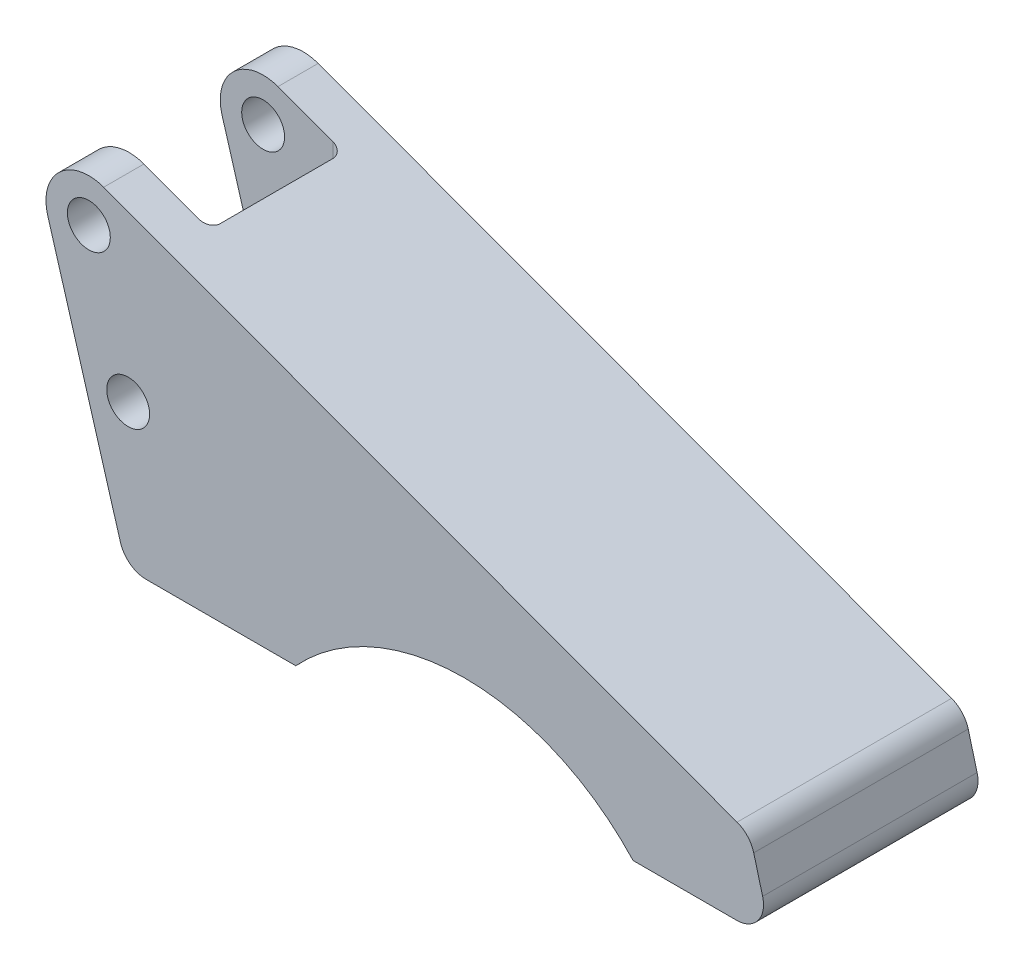
from build123d import *

# Parameters (mm, degrees)
SKETCH1_R               = 4
BOSS_EXTRUDE1_DEPTH     = 40
FILLET1_R               = 5
SKETCH2_W               = 25
SKETCH2_H               = 25
CUT_EXTRUDE1_DEPTH      = 9
CUT_EXTRUDE1_DEPTH_BACK = 52.87
FILLET2_R               = 2


with BuildPart() as part:
    # Sketch1 → Boss-Extrude1 (new body)
    with BuildSketch(Plane.XY):
        with BuildLine():
            Line((6.947546174, -51.87), (-7.673645346, -2.261673518))
            ThreePointArc((-7.673645346, -2.261673518), (-5.46693216, 5.840603801), (2.763356291, 7.507586963))
            Line((2.763356291, 7.507586963), (123.33, -36.87))
            Line((123.33, -36.87), (127.33, -51.87))
            Line((127.33, -51.87), (101.494792958, -51.87))
            ThreePointArc((101.494792958, -51.87), (70.04, -38.09), (38.585207042, -51.87))
            Line((38.585207042, -51.87), (6.947546174, -51.87))
        make_face()
        Circle(SKETCH1_R, mode=Mode.SUBTRACT)
        with Locations((7.33, -24.87)):
            Circle(SKETCH1_R, mode=Mode.SUBTRACT)
    extrude(amount=-BOSS_EXTRUDE1_DEPTH)

    # Fillet1
    fillet1_edges = [part.edges().sort_by_distance(p)[0] for p in [
        (6.947546174, -51.87, -20),
        (123.33, -36.87, -20),
        (127.33, -51.87, -20),
    ]]
    fillet(fillet1_edges, radius=FILLET1_R)

    # Sketch2 → Cut-Extrude1 (cut, two sides)
    with BuildSketch(Plane(origin=(0, 0, 0), x_dir=(1, 0, 0), z_dir=(0, 1, 0))) as cut_extrude1_sk:
        with Locations((2.5, 20)):
            Rectangle(SKETCH2_W, SKETCH2_H)
    extrude(amount=CUT_EXTRUDE1_DEPTH, mode=Mode.SUBTRACT)
    extrude(cut_extrude1_sk.sketch, amount=-CUT_EXTRUDE1_DEPTH_BACK, mode=Mode.SUBTRACT)

    # Fillet2
    fillet2_edges = [part.edges().sort_by_distance(p)[0] for p in [
        (15, -24.433208829, -7.5),
        (15, -24.433208829, -32.5),
    ]]
    fillet(fillet2_edges, radius=FILLET2_R)


solid = part.part
